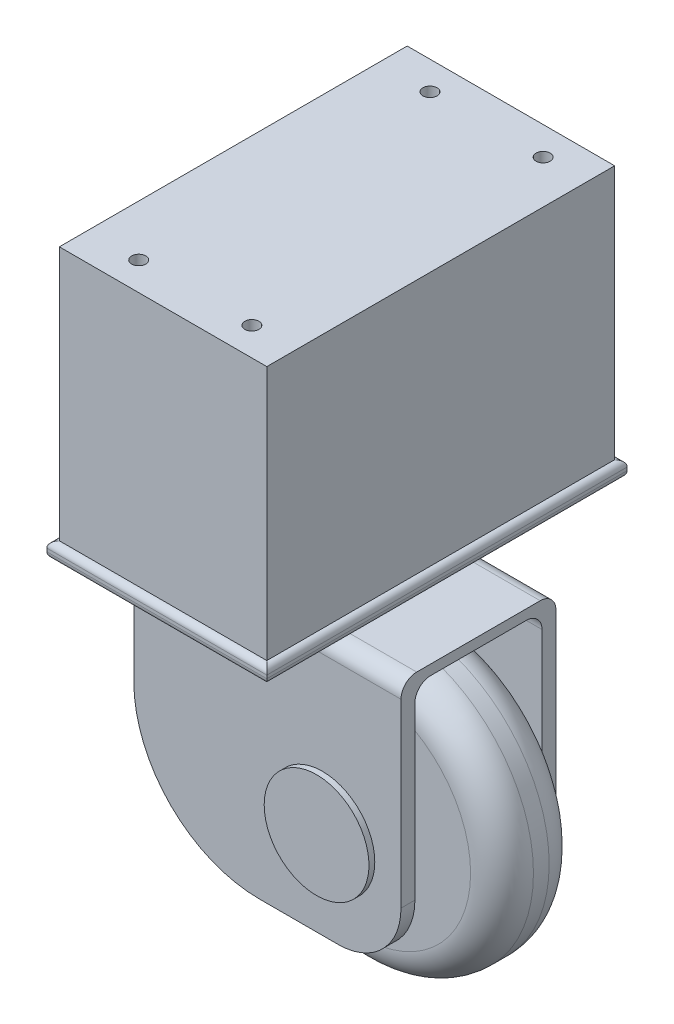
from build123d import *

# Parameters (mm, degrees)
SKETCH1_R                = 45
BOSS_EXTRUDE1_DEPTH      = 25
BOSS_EXTRUDE2_DEPTH      = 25
BOSS_EXTRUDE2_DEPTH_BACK = 60
SKETCH3_R                = 16.694420179
BOSS_EXTRUDE3_DEPTH      = 10
SKETCH4_W                = 70
SKETCH4_H                = 114.66
BOSS_EXTRUDE4_DEPTH      = 5
SKETCH5_R                = 16.667292011
BOSS_EXTRUDE5_DEPTH      = 14
BOSS_EXTRUDE5_DEPTH_BACK = 39
FILLET1_R                = 10
FILLET2_R                = 40
FILLET3_R                = 20
FILLET4_R                = 5
FILLET5_R                = 2
SCALE1_SCALE             = 1.111111111
SKETCH6_W                = 73.333333333
SKETCH6_H                = 122.955555555
BOSS_EXTRUDE6_DEPTH      = 90
SKETCH7_R                = 2.5
CUT_EXTRUDE1_DEPTH       = 239.92789275
CUT_EXTRUDE1_DEPTH_BACK  = 239.92789275


with BuildPart() as part:
    # Sketch1 → Boss-Extrude1 (new body)
    with BuildSketch(Plane.XY):
        Circle(SKETCH1_R)
    extrude(amount=BOSS_EXTRUDE1_DEPTH)



with BuildPart() as body_2:
    # Sketch2 → Boss-Extrude2 (new, two sides)
    with BuildSketch(Plane(origin=(0, 0, 0), x_dir=(0, 0, -1), z_dir=(1, 0, 0))) as boss_extrude2_sk:
        Polygon((-32.711176171, -28.552814356), (-32.711176171, 50.79995961), (7.711176171, 50.79995961), (7.711176171, -28.552814356), (12.147045523, -28.552814356), (12.147045523, 54.003643031), (-37.147045523, 54.003643031), (-37.147045523, -28.552814356), align=None)
    extrude(amount=BOSS_EXTRUDE2_DEPTH)
    extrude(boss_extrude2_sk.sketch, amount=-BOSS_EXTRUDE2_DEPTH_BACK)

    # Sketch3 → Boss-Extrude3 (add)
    with BuildSketch(Plane(origin=(0, 54.003643031, 0), x_dir=(1, 0, 0), z_dir=(0, 1, 0))):
        with Locations(Location((-20, -13.418920015, 0), (0, 0, 270))):
            Circle(SKETCH3_R)
    extrude(amount=BOSS_EXTRUDE3_DEPTH)

    # Sketch4 → Boss-Extrude4 (add)
    with BuildSketch(Plane(origin=(0, 64.003643031, 0), x_dir=(1, 0, 0), z_dir=(0, 1, 0))):
        with Locations((-20, -12.5)):
            Rectangle(SKETCH4_W, SKETCH4_H)
    extrude(amount=BOSS_EXTRUDE4_DEPTH)


with BuildPart() as part_1:
    add(part.part)

    add(body_2.part)  # Boss-Extrude5 merges body 2
    # Sketch5 → Boss-Extrude5 (add, two sides)
    with BuildSketch(Plane(origin=(0, 0, 0), x_dir=(-1, 0, 0), z_dir=(0, 0, -1))) as boss_extrude5_sk:
        with Locations(Location((0, 0, 0), (0, 0, 180))):
            Circle(SKETCH5_R)
    extrude(amount=BOSS_EXTRUDE5_DEPTH)
    extrude(boss_extrude5_sk.sketch, amount=-BOSS_EXTRUDE5_DEPTH_BACK)

    # Fillet1
    fillet1_edges = [part_1.edges().sort_by_distance(p)[0] for p in [
        (-45, 0, 0),
        (-45, 0, 25),
    ]]
    fillet(fillet1_edges, radius=FILLET1_R)

    # Fillet2
    fillet2_edges = [part_1.edges().sort_by_distance(p)[0] for p in [
        (-60, -28.552814356, 34.929110847),
        (-60, -28.552814356, -9.929110847),
    ]]
    fillet(fillet2_edges, radius=FILLET2_R)

    # Fillet3
    fillet3_edges = [part_1.edges().sort_by_distance(p)[0] for p in [
        (25, -28.552814356, 34.929110847),
        (25, -28.552814356, -9.929110847),
    ]]
    fillet(fillet3_edges, radius=FILLET3_R)

    # Fillet4
    fillet4_edges = [part_1.edges().sort_by_distance(p)[0] for p in [
        (-17.5, 54.003643031, 37.147045523),
        (-17.5, 54.003643031, -12.147045523),
        (-17.5, 50.79995961, -7.711176171),
        (-17.5, 50.79995961, 32.711176171),
    ]]
    fillet(fillet4_edges, radius=FILLET4_R)

    # Fillet5
    fillet5_edges = [part_1.edges().sort_by_distance(p)[0] for p in [
        (-55, 64.003643031, 12.5),
        (-20, 64.003643031, 69.83),
        (15, 64.003643031, 12.5),
        (-20, 64.003643031, -44.83),
        (-55, 69.003643031, 12.5),
        (-20, 69.003643031, 69.83),
        (15, 69.003643031, 12.5),
        (-20, 69.003643031, -44.83),
    ]]
    fillet(fillet5_edges, radius=FILLET5_R)


with BuildPart() as part_2:
    # Scale1: scaled about (-7.475087619, 16.274033837, 12.528539565)
    add(part_1.part.scale(SCALE1_SCALE).moved(Location((0.830565291, -1.808225982, -1.392059952))))


with BuildPart() as boss_extrude6_tool:
    # Sketch6 → Boss-Extrude6 (new body)
    with BuildSketch(Plane(origin=(0, 74.862466329, 0), x_dir=(1, 0, 0), z_dir=(0, 1, 0))):
        with Locations((-21.391645996, -12.49682915)):
            Rectangle(SKETCH6_W, SKETCH6_H)
    extrude(amount=BOSS_EXTRUDE6_DEPTH)


with BuildPart() as part_3:
    add(part_2.part)


with BuildPart() as part_4:
    # Boss-Extrude6: joined with boss_extrude6_tool
    add(part_3.part.fuse(boss_extrude6_tool.part, tol=0.00001))

    # Sketch7 → Cut-Extrude1 (cut, two sides)
    with BuildSketch(Plane(origin=(0, 164.862466329, 0), x_dir=(1, 0, 0), z_dir=(0, 1, 0))) as cut_extrude1_sk:
        with Locations(Location((0, 38.980948628, 0), (0, 0, 270))):
            Circle(SKETCH7_R)
        with Locations(Location((-40, 38.980948628, 0), (0, 0, 270))):
            Circle(SKETCH7_R)
        with Locations(Location((0, -63.974606927, 0), (0, 0, 270))):
            Circle(SKETCH7_R)
        with Locations(Location((-40, -63.974606927, 0), (0, 0, 270))):
            Circle(SKETCH7_R)
    extrude(amount=CUT_EXTRUDE1_DEPTH, mode=Mode.SUBTRACT)
    extrude(cut_extrude1_sk.sketch, amount=-CUT_EXTRUDE1_DEPTH_BACK, mode=Mode.SUBTRACT)


solid = part_4.part
